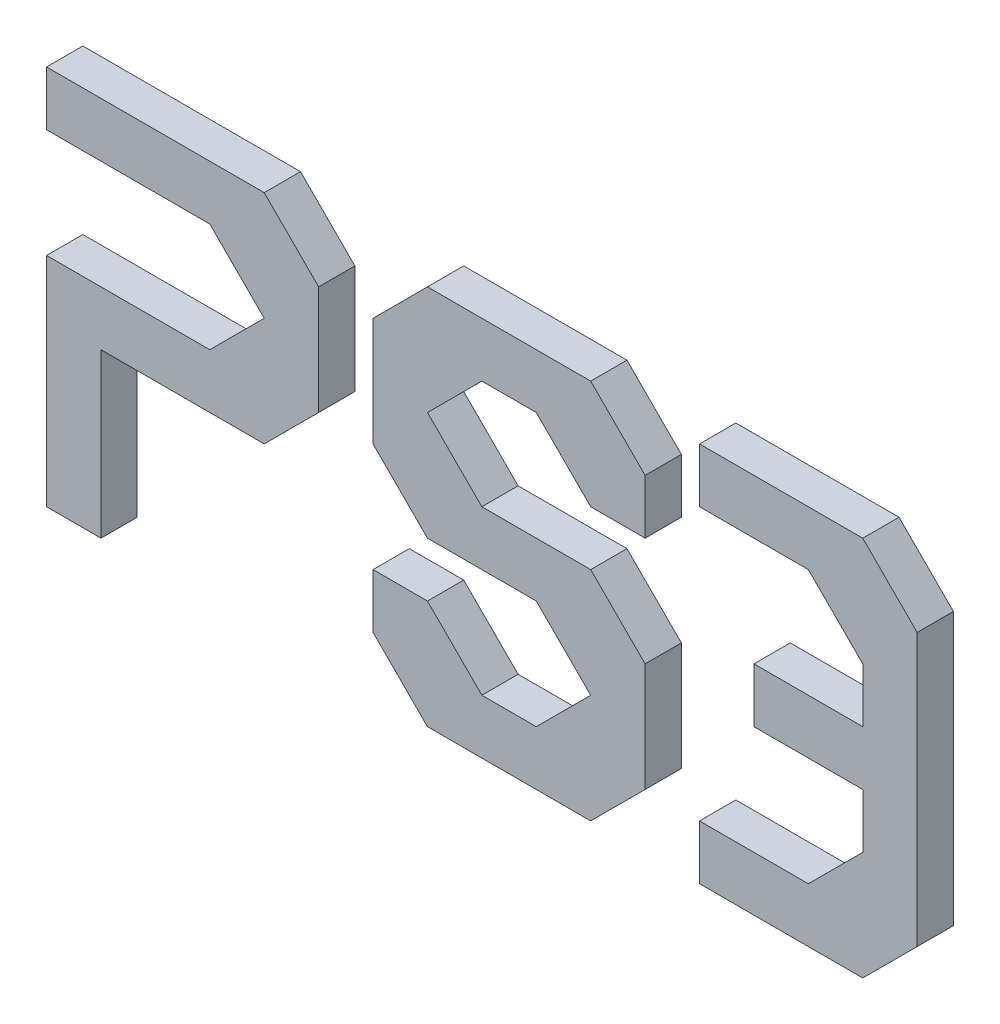
from build123d import *

# Parameters (mm, degrees)
EXTRUDE1_DEPTH   = 10
EXTRUDE1_2_DEPTH = 10
EXTRUDE1_3_DEPTH = 10


with BuildPart() as part:
    # Sketch2 → Extrude1 (new body)
    with BuildSketch(Plane.XY):
        Polygon((0, 90), (0, 105), (45, 105), (60, 105), (75, 90), (75, 60), (60, 45), (45, 45), (15, 45), (15, 0), (0, 0), (0, 60), (30, 60), (45, 60), (60, 75), (45, 90), (30, 90), align=None)
    extrude(amount=EXTRUDE1_DEPTH)


with BuildPart() as body_2:
    # Sketch2 → Extrude1 2 (new body)
    with BuildSketch(Plane.XY):
        Polygon((105, 30), (90, 30), (90, 15), (105, 0), (150, 0), (165, 15), (165, 45), (150, 60), (135, 60), (120, 60), (105, 75), (120, 90), (135, 90), (150, 75), (165, 75), (165, 90), (150, 105), (105, 105), (90, 90), (90, 60), (105, 45), (135, 45), (150, 30), (135, 15), (120, 15), align=None)
    extrude(amount=EXTRUDE1_2_DEPTH)


with BuildPart() as body_3:
    # Sketch2 → Extrude1 3 (new body)
    with BuildSketch(Plane.XY):
        Polygon((180, 15), (180, 0), (225, 0), (240, 15), (240, 90), (225, 105), (180, 105), (180, 90), (210, 90), (225, 75), (225, 60), (195, 60), (195, 45), (225, 45), (225, 30), (210, 15), align=None)
    extrude(amount=EXTRUDE1_3_DEPTH)


solid = Compound([part.part, body_2.part, body_3.part])
